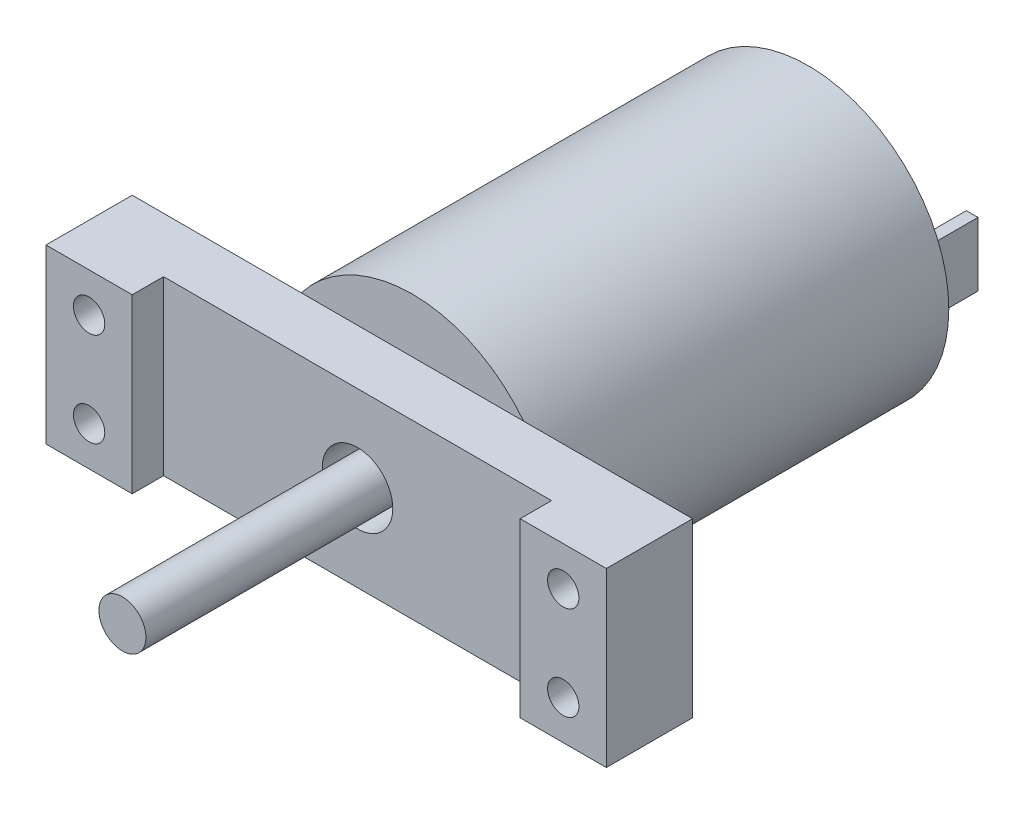
from build123d import *

# Parameters (mm, degrees)
SKETCH1_R           = 17.95
BOSS_EXTRUDE1_DEPTH = 50.5
SKETCH2_R           = 3
BOSS_EXTRUDE2_DEPTH = 37
SKETCH3_W           = 71.5
SKETCH3_H           = 22
SKETCH3_R           = 4.5
BOSS_EXTRUDE3_DEPTH = 7
SKETCH4_W           = 11
SKETCH4_H           = 22
BOSS_EXTRUDE4_DEPTH = 4
SKETCH5_R           = 2
CUT_EXTRUDE1_DEPTH  = 11
SKETCH6_W           = 1.486858086
SKETCH6_H           = 8.145396468
SKETCH6_W_2         = 1.874734108
BOSS_EXTRUDE6_DEPTH = 7


with BuildPart() as part:
    # Sketch1 → Boss-Extrude1 (new body)
    with BuildSketch(Plane.XY):
        Circle(SKETCH1_R)
    extrude(amount=BOSS_EXTRUDE1_DEPTH)

    # Sketch2 → Boss-Extrude2 (add)
    with BuildSketch(Plane.XY.offset(50.5)):
        Circle(SKETCH2_R)
    extrude(amount=BOSS_EXTRUDE2_DEPTH)

    # Sketch3 → Boss-Extrude3 (add)
    with BuildSketch(Plane.XY.offset(50.5)):
        Rectangle(SKETCH3_W, SKETCH3_H)
        Circle(SKETCH3_R, mode=Mode.SUBTRACT)
    extrude(amount=BOSS_EXTRUDE3_DEPTH)

    # Sketch4 → Boss-Extrude4 (add)
    with BuildSketch(Plane.XY.offset(57.5)):
        with Locations((-30.25, 0)):
            Rectangle(SKETCH4_W, SKETCH4_H)
        with Locations((30.25, 0)):
            Rectangle(SKETCH4_W, SKETCH4_H)
    extrude(amount=BOSS_EXTRUDE4_DEPTH)

    # Sketch5 → Cut-Extrude1 (cut)
    with BuildSketch(Plane.XY.offset(61.5)):
        with Locations((-30.25, 6)):
            Circle(SKETCH5_R)
        with Locations((-30.25, -6)):
            Circle(SKETCH5_R)
        with Locations((30.25, -6)):
            Circle(SKETCH5_R)
        with Locations((30.25, 6)):
            Circle(SKETCH5_R)
    extrude(amount=-CUT_EXTRUDE1_DEPTH, mode=Mode.SUBTRACT)

    # Sketch6 → Boss-Extrude6 (add)
    with BuildSketch(Plane(origin=(0, 0, 0), x_dir=(-1, 0, 0), z_dir=(0, 0, -1))):
        with Locations((-13.9312138, 0.937367054)):
            Rectangle(SKETCH6_W, SKETCH6_H)
        with Locations((13.090815752, 0.937367054)):
            Rectangle(SKETCH6_W_2, SKETCH6_H)
    extrude(amount=BOSS_EXTRUDE6_DEPTH)


solid = part.part
